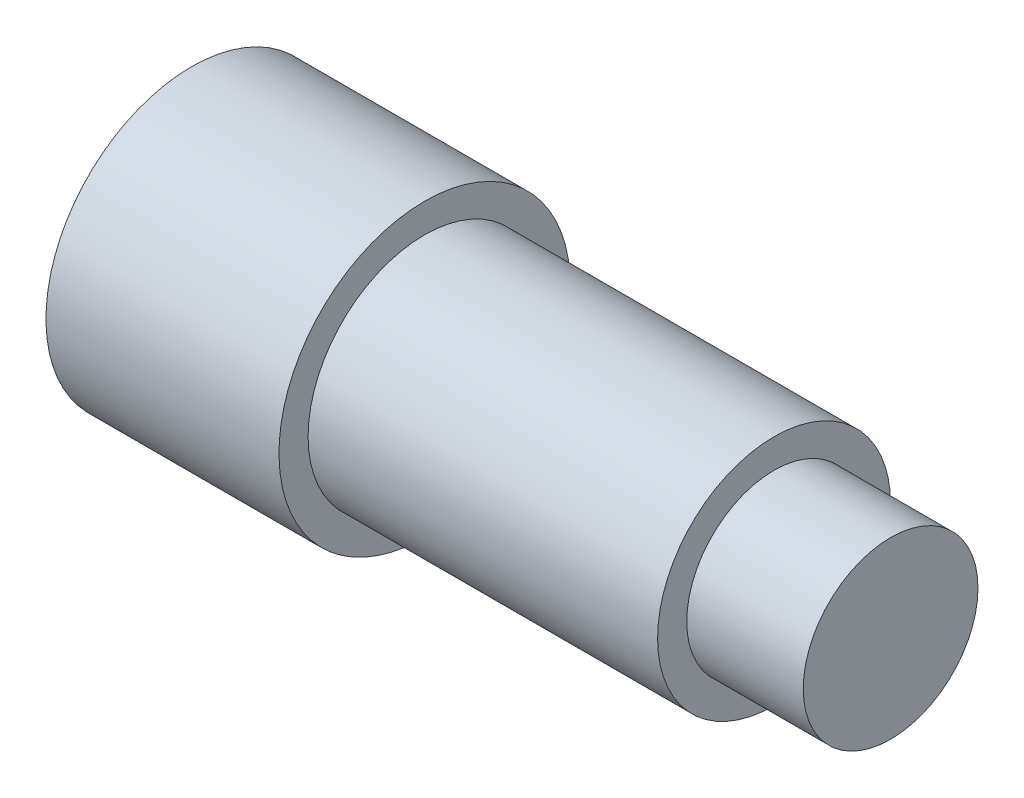
from build123d import *


with BuildPart() as part:
    # Esquisse1 → Révolution1 (revolve)
    with BuildSketch(Plane.XY):
        Polygon((0, 0), (0, 2.5), (4, 2.5), (4, 2), (10, 2), (10, 1.5), (12, 1.5), (12, 0), align=None)
    revolve(axis=Axis((12, 0, 0), (-1, 0, 0)))


solid = part.part
